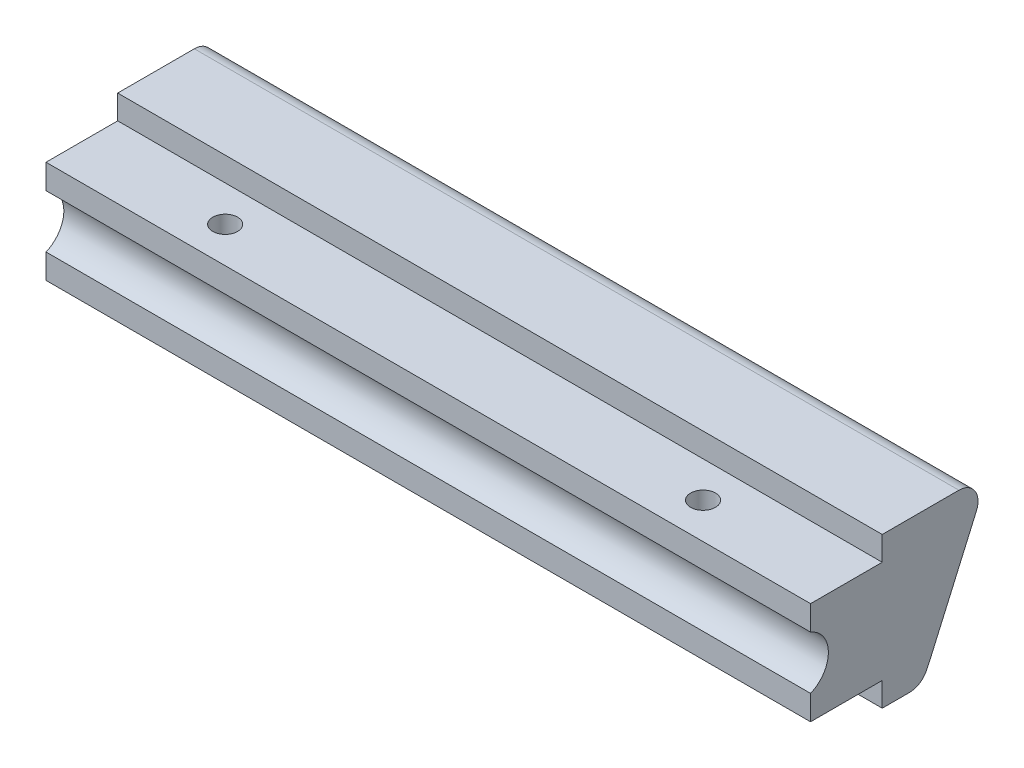
from build123d import *

# Parameters (mm, degrees)
BOSS_EXTRUDE1_DEPTH = 101.6
CUT_EXTRUDE2_DEPTH  = 101.6
SKETCH5_R           = 1.651
CUT_EXTRUDE3_DEPTH  = 13.5992
FILLET1_R           = 2.54


with BuildPart() as part:
    # Sketch1 → Boss-Extrude1 (new body)
    with BuildSketch(Plane(origin=(0, 0, 0), x_dir=(0, 0, -1), z_dir=(1, 0, 0))):
        with BuildLine():
            Line((0, 16.7996), (0, 3.2004))
            Line((0, 3.2004), (9.525, 3.2004))
            Line((9.525, 3.2004), (9.525, 0))
            Line((9.525, 0), (14.605, 0))
            ThreePointArc((14.605, 0), (15.279774052, 1.174548121), (15.868724182, 2.394392806))
            Line((15.868724182, 2.394392806), (23.603930172, 20))
            Line((23.603930172, 20), (9.525, 20))
            Line((9.525, 20), (9.525, 16.7996))
            Line((9.525, 16.7996), (0, 16.7996))
        make_face()
    extrude(amount=BOSS_EXTRUDE1_DEPTH)

    # Sketch4 → Cut-Extrude2 (cut)
    with BuildSketch(Plane.ZY):
        with BuildLine():
            Line((0, 13.526281186), (0, 6.473718814))
            ThreePointArc((0, 6.473718814), (-2.36728, 10), (0, 13.526281186))
        make_face()
    extrude(amount=-CUT_EXTRUDE2_DEPTH, mode=Mode.SUBTRACT)

    # Sketch5 → Cut-Extrude3 (cut)
    with BuildSketch(Plane(origin=(0, 16.7996, 0), x_dir=(1, 0, 0), z_dir=(0, 1, 0))):
        with Locations((19.05, 4.7625)):
            Circle(SKETCH5_R)
        with Locations((82.55, 4.7625)):
            Circle(SKETCH5_R)
    extrude(amount=-CUT_EXTRUDE3_DEPTH, mode=Mode.SUBTRACT)

    # Fillet1
    fillet1_edges = [part.edges().sort_by_distance(p)[0] for p in [
        (50.8, 20, -23.603930172),
        (50.8, 0, -14.605),
    ]]
    fillet(fillet1_edges, radius=FILLET1_R)


solid = part.part
